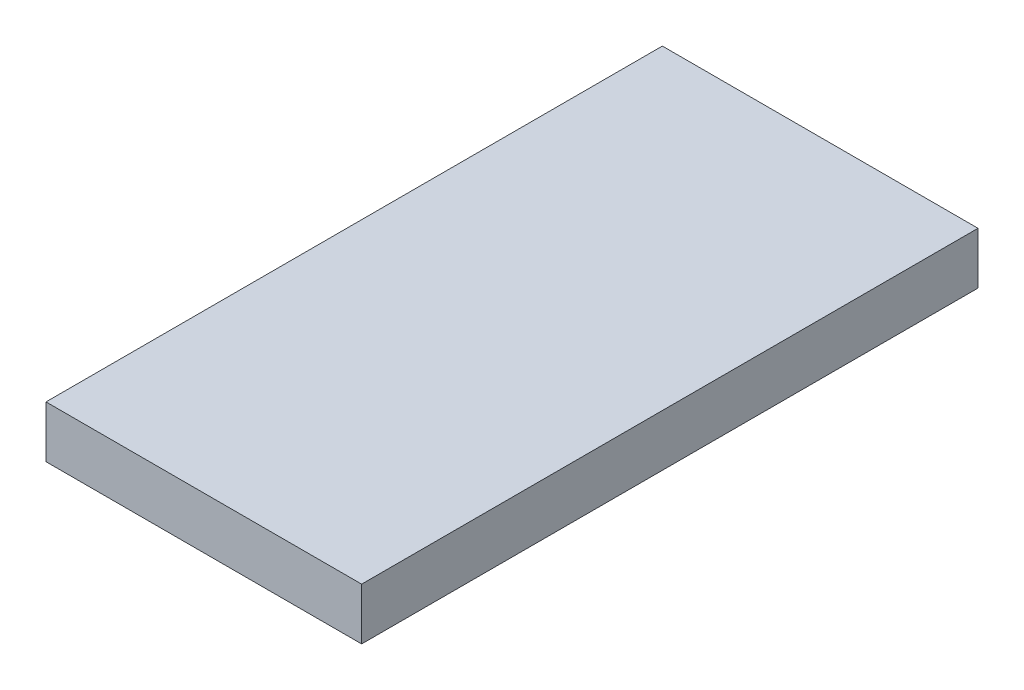
from build123d import *

# Parameters (mm, degrees)
SKETCH1_W           = 66.04
SKETCH1_H           = 128.96
BOSS_EXTRUDE1_DEPTH = 10.84


with BuildPart() as part:
    # Sketch1 → Boss-Extrude1 (new body)
    with BuildSketch(Plane(origin=(0, 0, 0), x_dir=(1, 0, 0), z_dir=(0, 1, 0))):
        with Locations((33.02, 64.48)):
            Rectangle(SKETCH1_W, SKETCH1_H)
    extrude(amount=BOSS_EXTRUDE1_DEPTH)


solid = part.part
